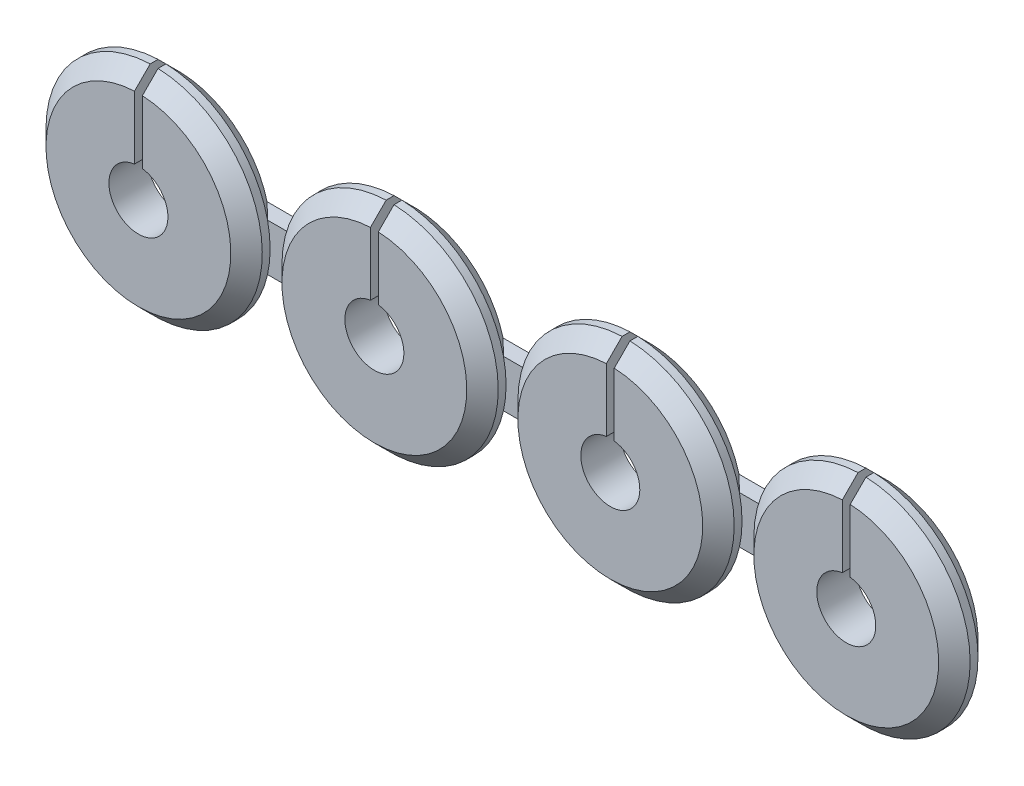
from build123d import *

# Parameters (mm, degrees)
SKETCH1_R           = 5.5
SKETCH1_R_2         = 1.5
BOSS_EXTRUDE1_DEPTH = 2
SKETCH2_W           = 0.4
SKETCH2_H           = 4.013393125
CUT_EXTRUDE1_DEPTH  = 9.031189202
CHAMFER1_SIZE       = 0.8
LPATTERN1_COUNT     = 4
LPATTERN1_PITCH     = 12
SKETCH3_W           = 2.911545786
SKETCH3_H           = 2.4
BOSS_EXTRUDE2_DEPTH = 0.8


with BuildPart() as part:
    # Sketch1 → Boss-Extrude1 (new body)
    with BuildSketch(Plane.XY):
        Circle(SKETCH1_R)
        Circle(SKETCH1_R_2, mode=Mode.SUBTRACT)
    extrude(amount=BOSS_EXTRUDE1_DEPTH)

    # Sketch2 → Cut-Extrude1 (cut, through all)
    with BuildSketch(Plane.XY.offset(2)):
        with Locations((0, 3.493303437)):
            Rectangle(SKETCH2_W, SKETCH2_H)
    extrude(amount=-CUT_EXTRUDE1_DEPTH, mode=Mode.SUBTRACT)

    # Chamfer1
    chamfer1_edges = [part.edges().sort_by_distance(p)[0] for p in [
        (-3.817721834, -3.959166579, 0),
        (-3.817721834, -3.959166579, 2),
    ]]
    chamfer(chamfer1_edges, length=CHAMFER1_SIZE)


with BuildPart() as lpattern1_1:
    # LPattern1: pattern copy
    add(part.part.moved(Location(Vector(1, 0, 0) * (1 * LPATTERN1_PITCH))))


with BuildPart() as lpattern1_2:
    # LPattern1: pattern copy
    add(part.part.moved(Location(Vector(1, 0, 0) * (2 * LPATTERN1_PITCH))))


with BuildPart() as lpattern1_3:
    # LPattern1: pattern copy
    add(part.part.moved(Location(Vector(1, 0, 0) * (3 * LPATTERN1_PITCH))))


with BuildPart() as part_1:
    add(part.part)

    add(lpattern1_1.part)  # Boss-Extrude2 merges LPattern1_1

    add(lpattern1_2.part)  # Boss-Extrude2 merges LPattern1_2

    add(lpattern1_3.part)  # Boss-Extrude2 merges LPattern1_3
    # Sketch3 → Boss-Extrude2 (add)
    with BuildSketch(Plane(origin=(0, 0, 0), x_dir=(-1, 0, 0), z_dir=(0, 0, -1))):
        with Locations((-18, 0)):
            Rectangle(SKETCH3_W, SKETCH3_H)
        with Locations((-6, 0)):
            Rectangle(SKETCH3_W, SKETCH3_H)
        with Locations((-30, 0)):
            Rectangle(SKETCH3_W, SKETCH3_H)
    extrude(amount=-BOSS_EXTRUDE2_DEPTH)


solid = part_1.part
